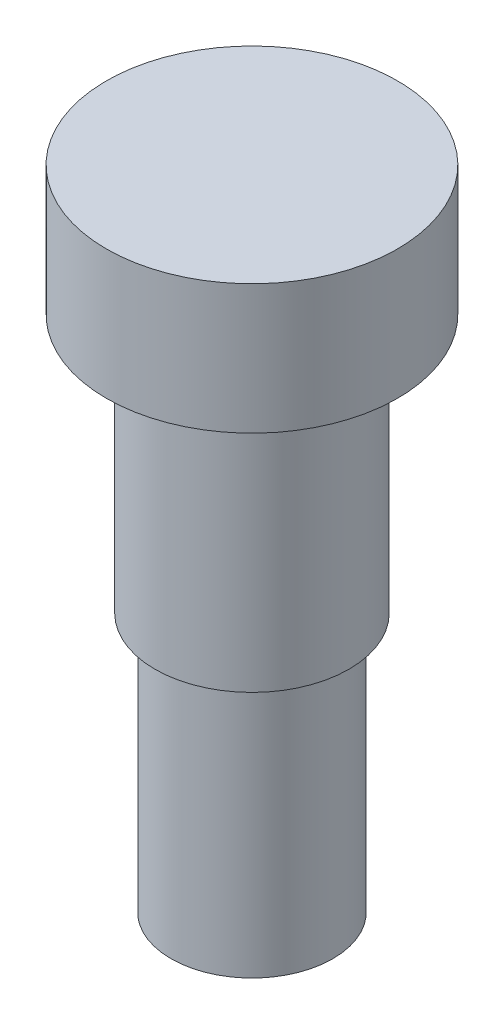
from build123d import *


with BuildPart() as part:
    # profile → Base-Revolve (revolve)
    with BuildSketch(Plane.XY):
        Polygon((0, 6.35), (7.14375, 6.35), (7.14375, 0), (4.7625, 0), (4.7625, -12.7), (3.96875, -12.7), (3.96875, -25.4), (0, -25.4), align=None)
    revolve(axis=Axis((0, 24.832359952, 0), (0, -1, 0)))


solid = part.part
